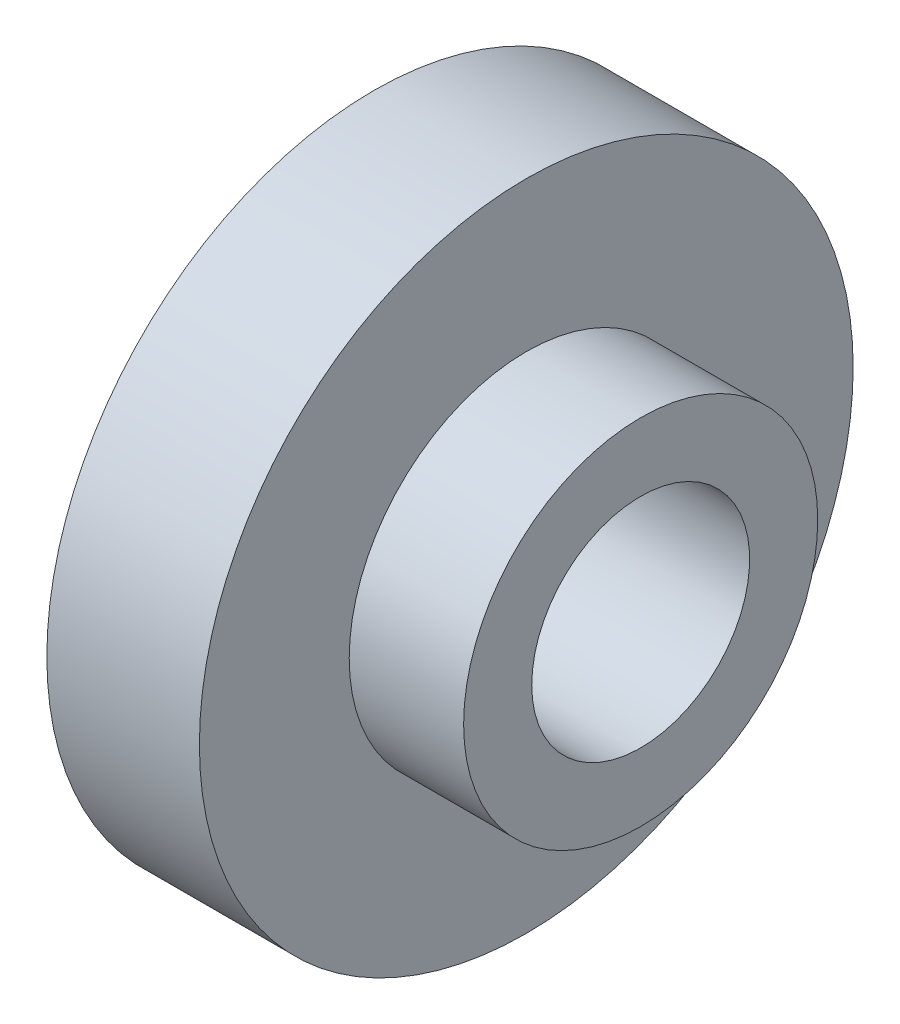
from build123d import *


with BuildPart() as part:
    # Эскиз1 → Повернуть1 (revolve)
    with BuildSketch(Plane.XY):
        Polygon((0, 2.4), (0, 6), (2.8, 6), (2.8, 3.25), (4.9, 3.25), (4.9, 2), (0.4, 2), align=None)
    revolve(axis=Axis((0, 0, 0), (1, 0, 0)))


solid = part.part
